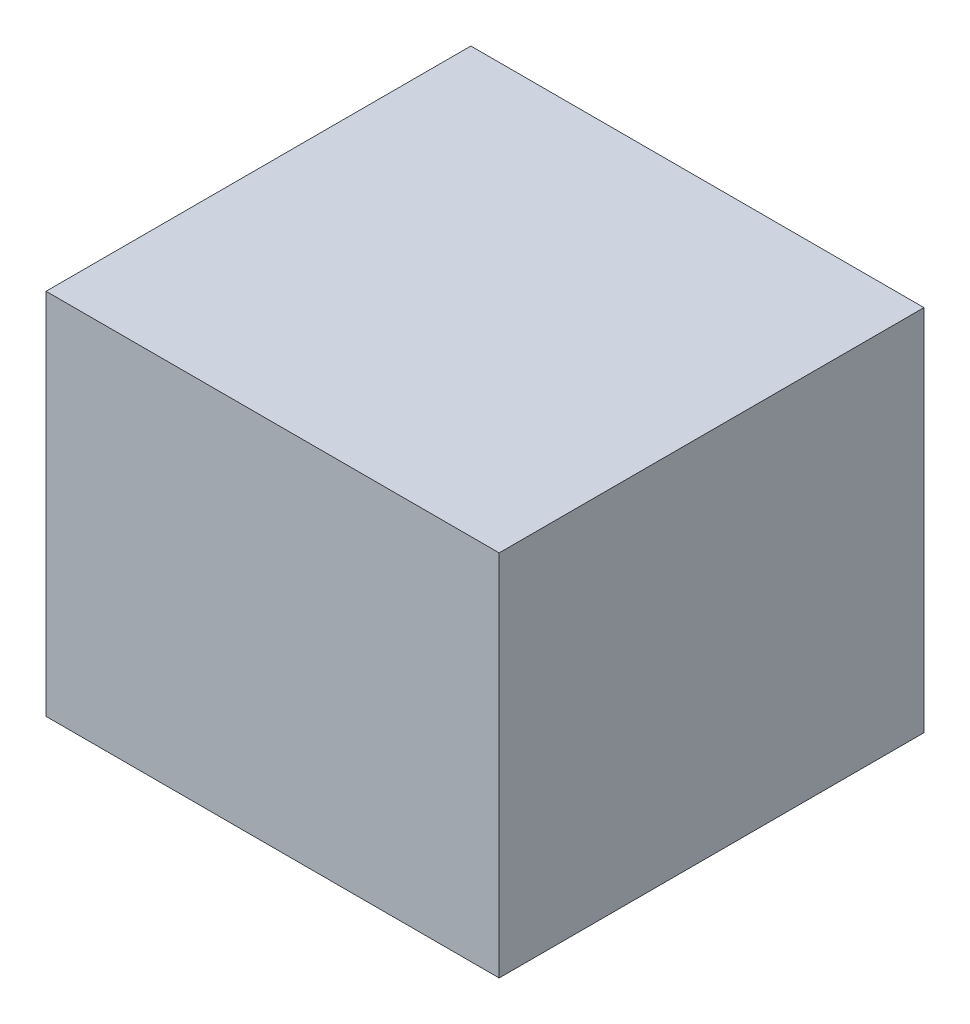
from build123d import *

# Parameters (mm, degrees)
SKETCH1_W           = 50.8
SKETCH1_H           = 41.275
BOSS_EXTRUDE1_DEPTH = 47.625


with BuildPart() as part:
    # Sketch1 → Boss-Extrude1 (new body)
    with BuildSketch(Plane.XY):
        with Locations((25.4, -20.6375)):
            Rectangle(SKETCH1_W, SKETCH1_H)
    extrude(amount=BOSS_EXTRUDE1_DEPTH)


solid = part.part
